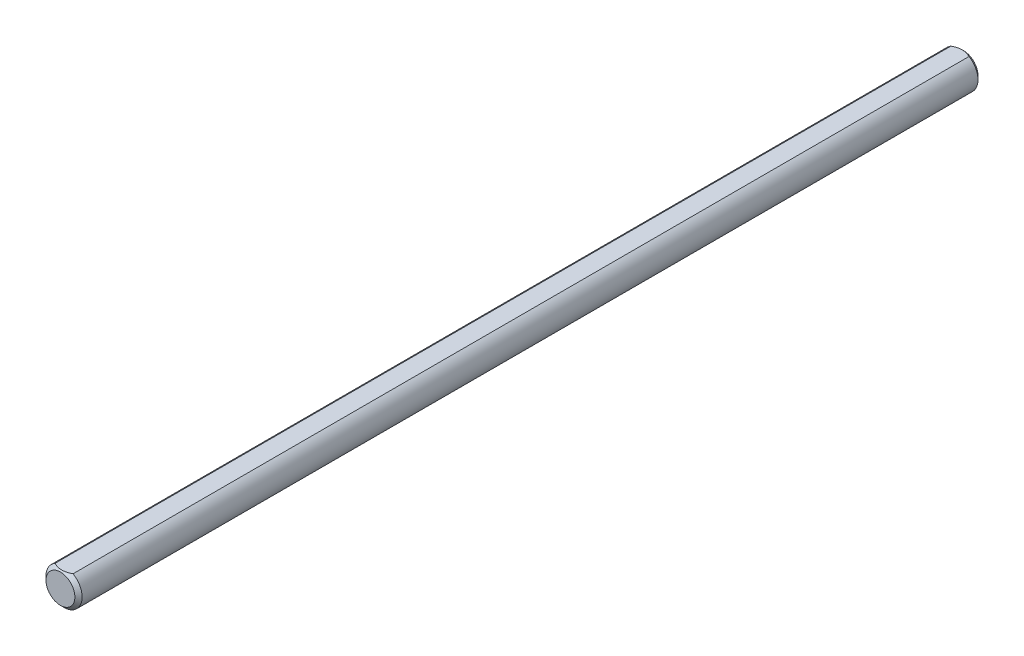
from build123d import *

# Parameters (mm, degrees)
SKETCH1_R           = 3.175
EXTRUDE1_DEPTH      = 79.375
CHAMFER1_SIZE       = 0.635
EXTRUDE7_DEPTH      = 80.375
EXTRUDE7_DEPTH_BACK = 80.375


with BuildPart() as part:
    # Sketch1 → Extrude1 (new body, symmetric)
    with BuildSketch(Plane.XY):
        Circle(SKETCH1_R)
    extrude(amount=EXTRUDE1_DEPTH, both=True)

    # Chamfer1
    chamfer1_edges = [part.edges().sort_by_distance(p)[0] for p in [
        (-3.175, 0, -79.375),
        (-3.175, 0, 79.375),
    ]]
    chamfer(chamfer1_edges, length=CHAMFER1_SIZE)

    # Sketch13 → Extrude7 (cut, two sides)
    with BuildSketch(Plane.XY) as extrude7_sk:
        with BuildLine():
            Line((-1.5875, 2.749630657), (1.5875, 2.749630657))
            ThreePointArc((1.5875, 2.749630657), (0, 3.175), (-1.5875, 2.749630657))
        make_face()
    extrude(amount=EXTRUDE7_DEPTH, mode=Mode.SUBTRACT)
    extrude(extrude7_sk.sketch, amount=-EXTRUDE7_DEPTH_BACK, mode=Mode.SUBTRACT)


solid = part.part
